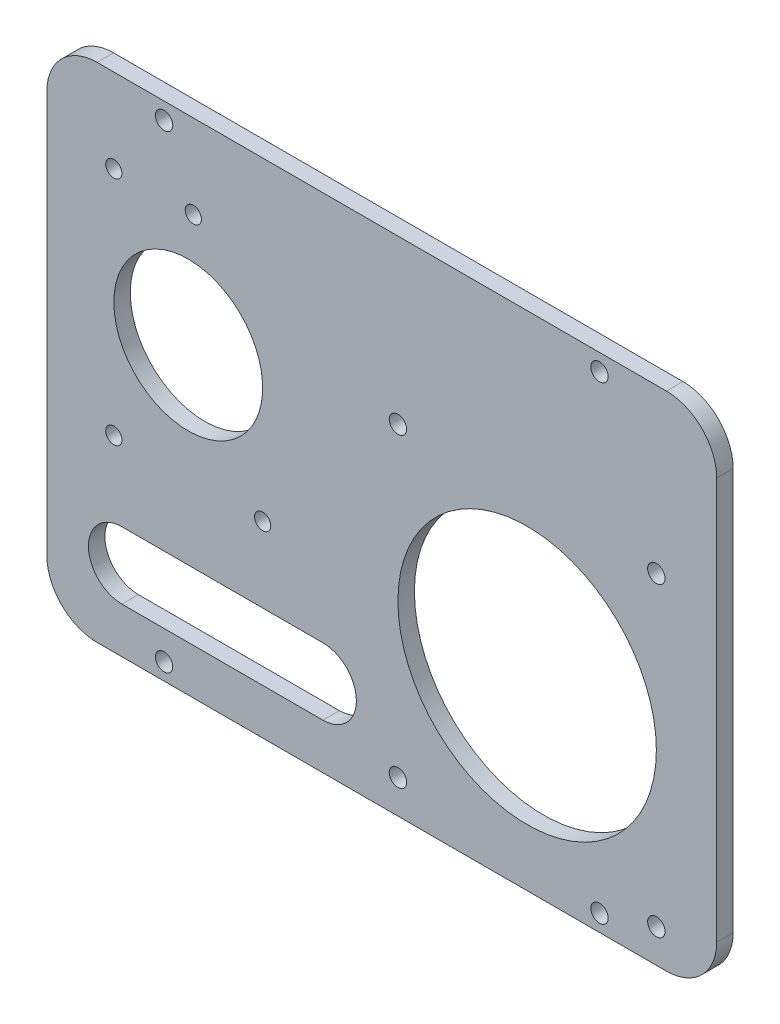
from build123d import *

# Parameters (mm, degrees)
SALIENTE_EXTRUIR1_DEPTH = 3.1242
CROQUIS2_R              = 1.651
CORTAR_EXTRUIR1_DEPTH   = 4.1242
CROQUIS3_R              = 1.651
CORTAR_EXTRUIR2_DEPTH   = 3.1242
CROQUIS4_R              = 14.1097
CROQUIS4_R_2            = 1.5367
CORTAR_EXTRUIR3_DEPTH   = 4.1242


with BuildPart() as part:
    # Croquis1 → Saliente-Extruir1 (new body)
    with BuildSketch(Plane.XY):
        with BuildLine():
            Line((-53.975, -47.625), (53.975, -47.625))
            ThreePointArc((53.975, -47.625), (60.710192091, -44.835192091), (63.5, -38.1))
            Line((63.5, -38.1), (63.5, 38.1))
            ThreePointArc((63.5, 38.1), (60.710192091, 44.835192091), (53.975, 47.625))
            Line((53.975, 47.625), (-53.975, 47.625))
            ThreePointArc((-53.975, 47.625), (-60.710192091, 44.835192091), (-63.5, 38.1))
            Line((-63.5, 38.1), (-63.5, -38.1))
            ThreePointArc((-63.5, -38.1), (-60.710192091, -44.835192091), (-53.975, -47.625))
        make_face()
    extrude(amount=SALIENTE_EXTRUIR1_DEPTH)

    # Croquis2 → Cortar-Extruir1 (cut, through all)
    with BuildSketch(Plane.XY.offset(3.1242)):
        with Locations((-41.275, 44.45)):
            Circle(CROQUIS2_R)
        with Locations((41.275, 44.45)):
            Circle(CROQUIS2_R)
        with Locations((41.275, -44.45)):
            Circle(CROQUIS2_R)
        with Locations((-41.275, -44.45)):
            Circle(CROQUIS2_R)
    extrude(amount=-CORTAR_EXTRUIR1_DEPTH, mode=Mode.SUBTRACT)

    # Croquis3 → Cortar-Extruir2 (cut)
    with BuildSketch(Plane(origin=(0, 0, 0), x_dir=(-1, 0, 0), z_dir=(0, 0, -1))):
        with BuildLine():
            ThreePointArc((-27.5625, 12.225), (-44.886616139, 5.049116139), (-52.0625, -12.275))
            Line((-52.0625, -12.275), (-27.5625, -12.275))
            Line((-27.5625, -12.275), (-27.5625, 12.225))
        make_face()
        with BuildLine():
            Line((-27.5625, -12.275), (-52.0625, -12.275))
            ThreePointArc((-52.0625, -12.275), (-44.886616139, -29.599116139), (-27.5625, -36.775))
            Line((-27.5625, -36.775), (-27.5625, -12.275))
        make_face()
        with BuildLine():
            Line((-27.5625, 12.225), (-27.5625, -12.275))
            Line((-27.5625, -12.275), (-3.0625, -12.275))
            ThreePointArc((-3.0625, -12.275), (-10.238383861, 5.049116139), (-27.5625, 12.225))
        make_face()
        with BuildLine():
            Line((-3.0625, -12.275), (-27.5625, -12.275))
            Line((-27.5625, -12.275), (-27.5625, -36.775))
            ThreePointArc((-27.5625, -36.775), (-10.238383861, -29.599116139), (-3.0625, -12.275))
        make_face()
        with Locations((-3.0625, 16.725)):
            Circle(CROQUIS3_R)
        with Locations((-52.0625, 16.725)):
            Circle(CROQUIS3_R)
        with Locations((-52.0625, -41.275)):
            Circle(CROQUIS3_R)
        with Locations((-3.0625, -41.275)):
            Circle(CROQUIS3_R)
    extrude(amount=-CORTAR_EXTRUIR2_DEPTH, mode=Mode.SUBTRACT)

    # Croquis4 → Cortar-Extruir3 (cut, through all)
    with BuildSketch(Plane(origin=(0, 0, 0), x_dir=(-1, 0, 0), z_dir=(0, 0, -1))):
        with Locations((36.6903, 9.8552)):
            Circle(CROQUIS4_R)
        with Locations((35.7378, 31.75)):
            Circle(CROQUIS4_R_2)
        with Locations((50.8, 31.75)):
            Circle(CROQUIS4_R_2)
        with Locations((50.8, -12.0396)):
            Circle(CROQUIS4_R_2)
        with Locations((22.5806, -12.0396)):
            Circle(CROQUIS4_R_2)
        with BuildLine():
            Line((11.1633, -26.2763), (49.2633, -26.2763))
            ThreePointArc((49.2633, -26.2763), (55.6133, -32.6263), (49.2633, -38.9763))
            Line((49.2633, -38.9763), (11.1633, -38.9763))
            ThreePointArc((11.1633, -38.9763), (4.8133, -32.6263), (11.1633, -26.2763))
        make_face()
    extrude(amount=-CORTAR_EXTRUIR3_DEPTH, mode=Mode.SUBTRACT)


solid = part.part
